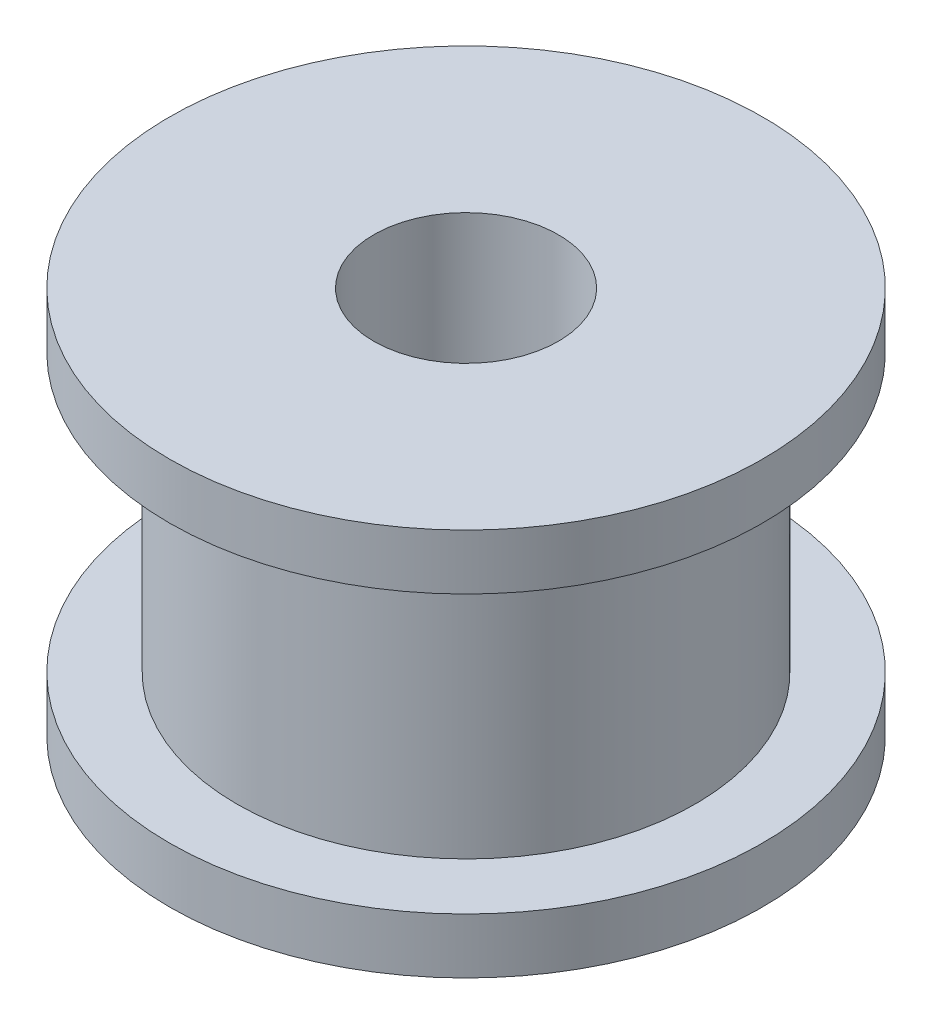
from build123d import *

# Parameters (mm, degrees)
SKETCH1_R           = 8.025
BOSS_EXTRUDE1_DEPTH = 1.5
SKETCH2_R           = 6.2
BOSS_EXTRUDE2_DEPTH = 7.5
SKETCH3_R           = 8.025
BOSS_EXTRUDE3_DEPTH = 1.5
SKETCH4_R           = 2.5
CUT_EXTRUDE1_DEPTH  = 11.5


with BuildPart() as part:
    # Sketch1 → Boss-Extrude1 (new body)
    with BuildSketch(Plane(origin=(0, 0, 0), x_dir=(1, 0, 0), z_dir=(0, 1, 0))):
        Circle(SKETCH1_R)
    extrude(amount=BOSS_EXTRUDE1_DEPTH)

    # Sketch2 → Boss-Extrude2 (add)
    with BuildSketch(Plane(origin=(0, 1.5, 0), x_dir=(1, 0, 0), z_dir=(0, 1, 0))):
        Circle(SKETCH2_R)
    extrude(amount=BOSS_EXTRUDE2_DEPTH)

    # Sketch3 → Boss-Extrude3 (add)
    with BuildSketch(Plane(origin=(0, 9, 0), x_dir=(1, 0, 0), z_dir=(0, 1, 0))):
        Circle(SKETCH3_R)
    extrude(amount=BOSS_EXTRUDE3_DEPTH)

    # Sketch4 → Cut-Extrude1 (cut, through all)
    with BuildSketch(Plane(origin=(0, 10.5, 0), x_dir=(1, 0, 0), z_dir=(0, 1, 0))):
        Circle(SKETCH4_R)
    extrude(amount=-CUT_EXTRUDE1_DEPTH, mode=Mode.SUBTRACT)


solid = part.part
